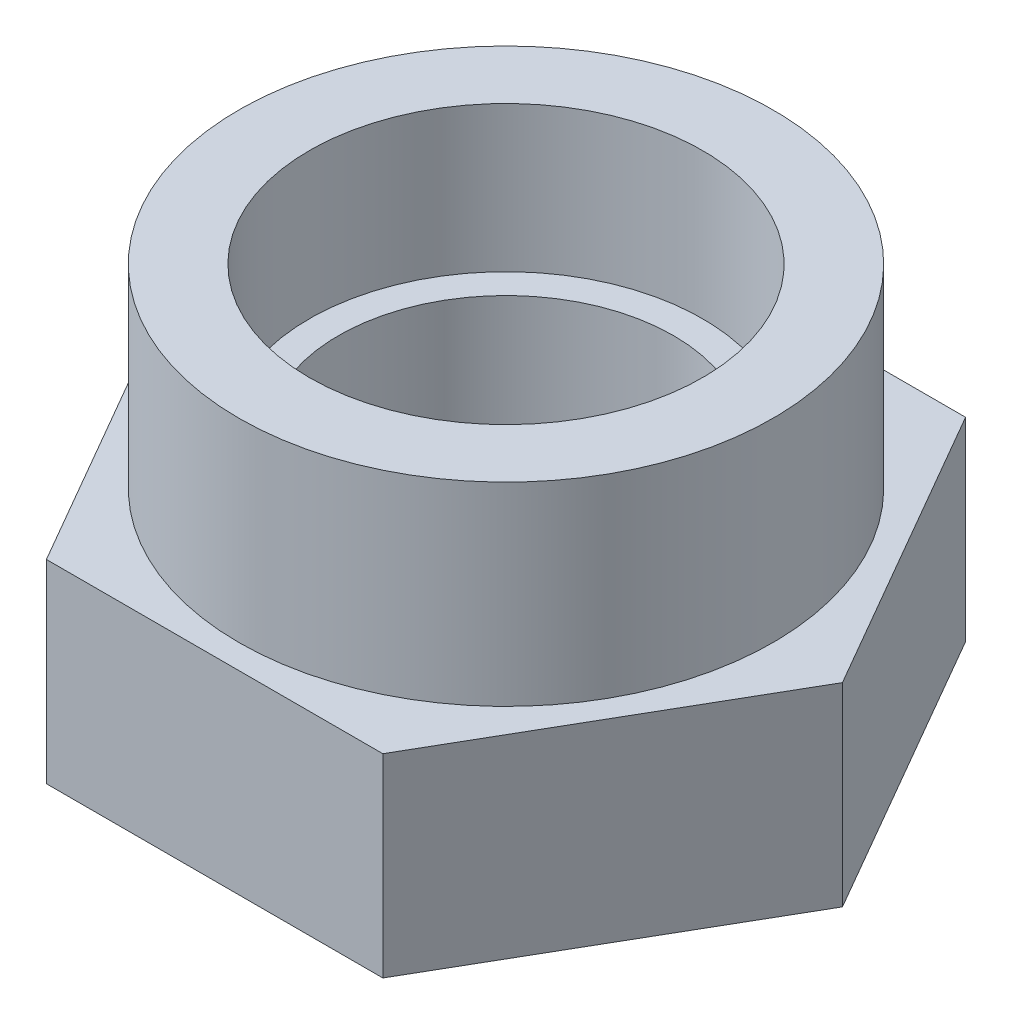
from build123d import *

# Parameters (mm, degrees)
SKETCH1_R           = 3.45
BOSS_EXTRUDE1_DEPTH = 8
SKETCH2_R           = 4.05
CUT_EXTRUDE1_DEPTH  = 3
SKETCH3_R           = 10
SKETCH3_R_2         = 5.5
CUT_EXTRUDE3_DEPTH  = 4


with BuildPart() as part:
    # Sketch1 → Boss-Extrude1 (new body)
    with BuildSketch(Plane(origin=(0, 0, 0), x_dir=(1, 0, 0), z_dir=(0, 1, 0))):
        Polygon((3.464101615, 6), (-3.464101615, 6), (-6.92820323, 0), (-3.464101615, -6), (3.464101615, -6), (6.92820323, 0), align=None)
        Circle(SKETCH1_R, mode=Mode.SUBTRACT)
    extrude(amount=BOSS_EXTRUDE1_DEPTH)

    # Sketch2 → Cut-Extrude1 (cut)
    with BuildSketch(Plane(origin=(0, 8, 0), x_dir=(1, 0, 0), z_dir=(0, 1, 0))):
        Circle(SKETCH2_R)
    extrude(amount=-CUT_EXTRUDE1_DEPTH, mode=Mode.SUBTRACT)

    # Sketch3 → Cut-Extrude3 (cut)
    with BuildSketch(Plane(origin=(0, 8, 0), x_dir=(1, 0, 0), z_dir=(0, 1, 0))):
        Circle(SKETCH3_R)
        Polygon((6.92820323, 0), (3.464101615, 6), (-3.464101615, 6), (-6.92820323, 0), (-3.464101615, -6), (3.464101615, -6), align=None, mode=Mode.SUBTRACT)
        Polygon((3.464101615, -6), (6.92820323, 0), (3.464101615, 6), (-3.464101615, 6), (-6.92820323, 0), (-3.464101615, -6), align=None)
        Circle(SKETCH3_R_2, mode=Mode.SUBTRACT)
    extrude(amount=-CUT_EXTRUDE3_DEPTH, mode=Mode.SUBTRACT)


solid = part.part
